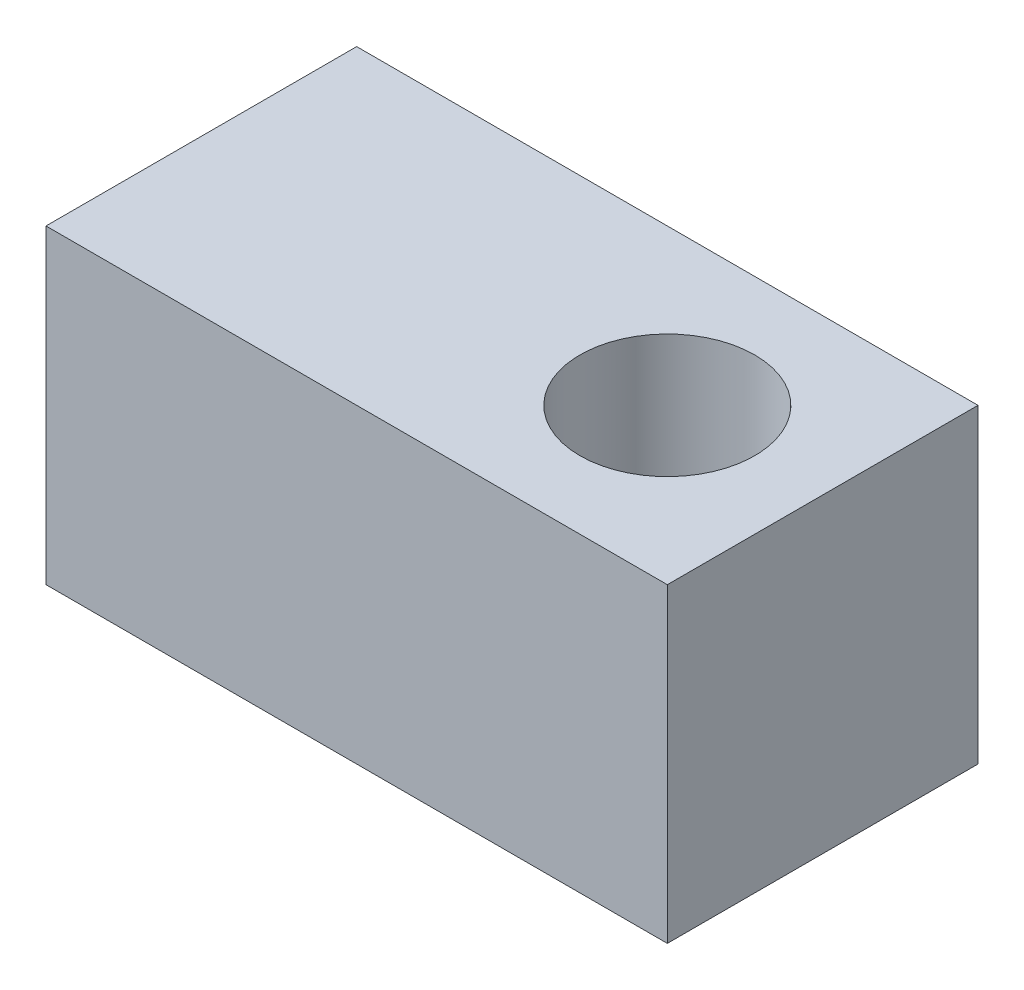
from build123d import *

# Parameters (mm, degrees)
SKETCH1_W                   = 101.6
SKETCH1_H                   = 50.8
BOSS_EXTRUDE1_DEPTH         = 50.8
CUT_EXTRUDE1_REACH          = 52.8
SKETCH2_R                   = 14.2875
F_1_4_28_TAPPED_HOLE1_D     = 5.4102
F_1_4_28_TAPPED_HOLE1_DEPTH = 28.12034
F_1_4_28_TAPPED_HOLE1_TIP   = 1.625388061


with BuildPart() as part:
    # Sketch1 → Boss-Extrude1 (new body)
    with BuildSketch(Plane(origin=(0, 0, 0), x_dir=(1, 0, 0), z_dir=(0, 1, 0))):
        Rectangle(SKETCH1_W, SKETCH1_H)
    extrude(amount=BOSS_EXTRUDE1_DEPTH)

    # Sketch2 → Cut-Extrude1 (cut, up to next)
    with BuildSketch(Plane(origin=(0, 50.8, 0), x_dir=(1, 0, 0), z_dir=(0, 1, 0)), mode=Mode.PRIVATE) as cut_extrude1_sk1:
        with Locations((25.4, 0)):
            Circle(SKETCH2_R)
    cut_extrude1_tool1 = extrude(cut_extrude1_sk1.sketch, amount=-CUT_EXTRUDE1_REACH, mode=Mode.PRIVATE) & part.part
    add(cut_extrude1_tool1.solids().sort_by_distance((25.4, 50.8, 0))[0], mode=Mode.SUBTRACT)

    # 1/4-28 Tapped Hole1
    with Locations(Plane(origin=(0, 0, 0), x_dir=(-1, 0, 0), z_dir=(0, -1, 0))):
        with Locations((44.45, 0)):
            Hole(F_1_4_28_TAPPED_HOLE1_D / 2, depth=F_1_4_28_TAPPED_HOLE1_DEPTH)
            with Locations((0, 0, -(F_1_4_28_TAPPED_HOLE1_DEPTH + F_1_4_28_TAPPED_HOLE1_TIP / 2))):  # 118° drill point
                Cone(0, F_1_4_28_TAPPED_HOLE1_D / 2, F_1_4_28_TAPPED_HOLE1_TIP, mode=Mode.SUBTRACT)


solid = part.part
